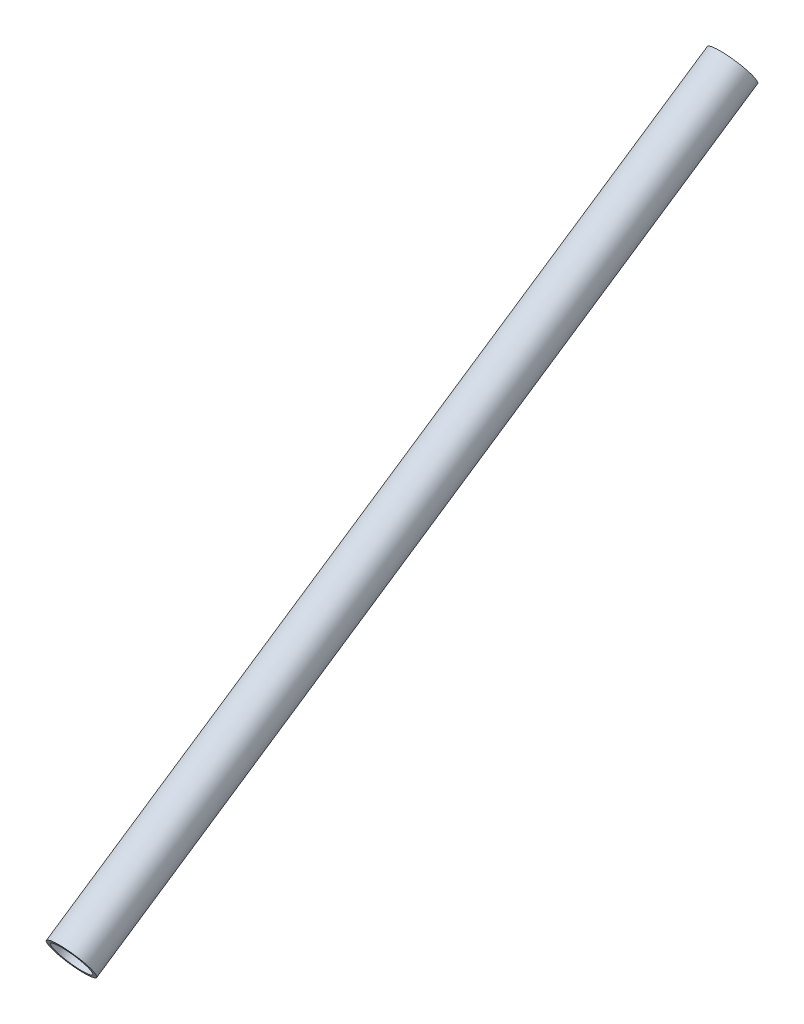
from build123d import *

# Parameters (mm, degrees)
SKETCH1_R                                   = 7.9375
SKETCH1_R_2                                 = 6.6929
ALROUNDTUBING_0_625_OD_X_0_049_WALL_1_DEPTH = 285.658093172


with BuildPart() as part:
    # Sketch1 → Alroundtubing 0.625 OD X 0.049 WALL(1) (new body)
    with BuildSketch(Plane(origin=(0, 474.17502327, 162.940184806), x_dir=(1, 0, 0), z_dir=(0, -0.5573511534959088, 0.8302768765278122))):
        Circle(SKETCH1_R)
        Circle(SKETCH1_R_2, mode=Mode.SUBTRACT)
    extrude(amount=ALROUNDTUBING_0_625_OD_X_0_049_WALL_1_DEPTH)


solid = part.part
